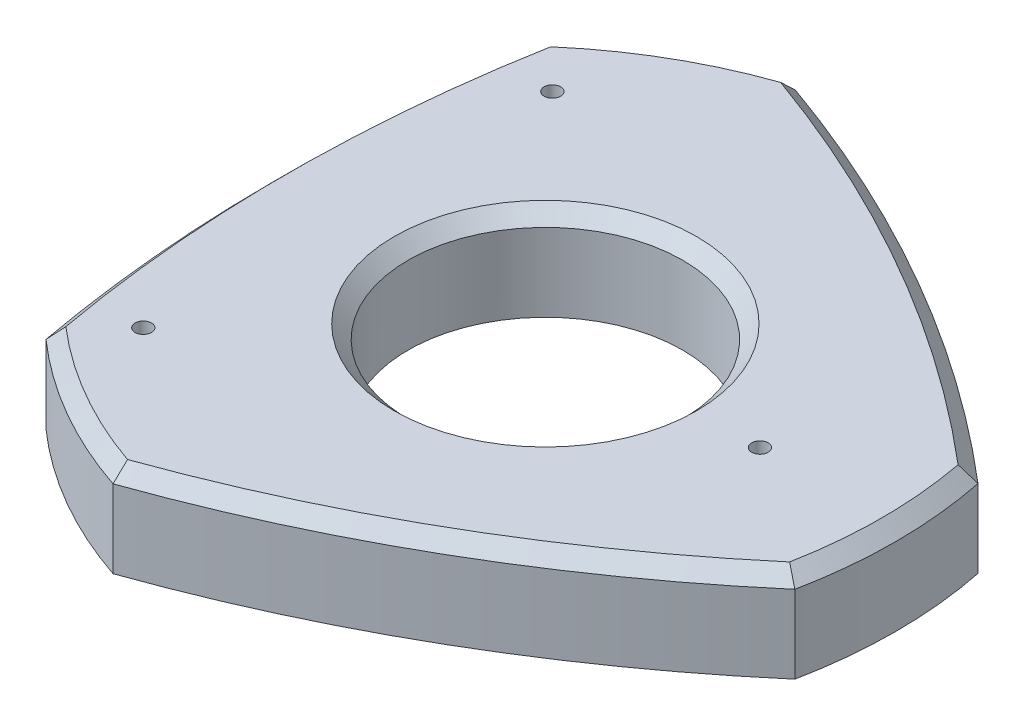
from build123d import *

# Parameters (mm, degrees)
SKETCH1_R            = 30
BOSS_EXTRUDE1_DEPTH  = 20
CHAMFER1_SIZE        = 3
M3_CLEARANCE_HOLE1_D = 3.6


with BuildPart() as part:
    # Sketch1 → Boss-Extrude1 (new body)
    with BuildSketch(Plane(origin=(0, 0, 0), x_dir=(1, 0, 0), z_dir=(0, 1, 0))):
        with BuildLine():
            ThreePointArc((-54.559600438, 54.5), (-59.559600438, 0), (-54.559600438, -54.5))
            ThreePointArc((-54.559600438, -54.5), (-38.239092363, -66.232050808), (-19.918584287, -74.5))
            ThreePointArc((-19.918584287, -74.5), (29.779800219, -51.580127019), (74.478184725, -20))
            ThreePointArc((74.478184725, -20), (76.478184725, 0), (74.478184725, 20))
            ThreePointArc((74.478184725, 20), (29.779800219, 51.580127019), (-19.918584287, 74.5))
            ThreePointArc((-19.918584287, 74.5), (-38.239092363, 66.232050808), (-54.559600438, 54.5))
        make_face()
        Circle(SKETCH1_R, mode=Mode.SUBTRACT)
    extrude(amount=BOSS_EXTRUDE1_DEPTH)

    # Chamfer1
    chamfer1_edges = [part.edges().sort_by_distance(p)[0] for p in [
        (-38.239092363, 20, 66.232050808),
        (29.779800219, 20, 51.580127019),
        (-30, 20, 0),
        (76.478184725, 20, 0),
        (29.779800219, 20, -51.580127019),
        (-38.239092363, 20, -66.232050808),
        (-59.559600438, 20, 0),
    ]]
    chamfer(chamfer1_edges, length=CHAMFER1_SIZE)

    # M3 Clearance Hole1 (through all)
    with Locations(Plane(origin=(0, 20, 0), x_dir=(1, 0, 0), z_dir=(0, 1, 0))):
        with Locations((0, 0), (-43.145434031, 44.670326137), (-43.145434031, -44.670326137), (46.854565969, 0)):
            Hole(M3_CLEARANCE_HOLE1_D / 2)


solid = part.part
